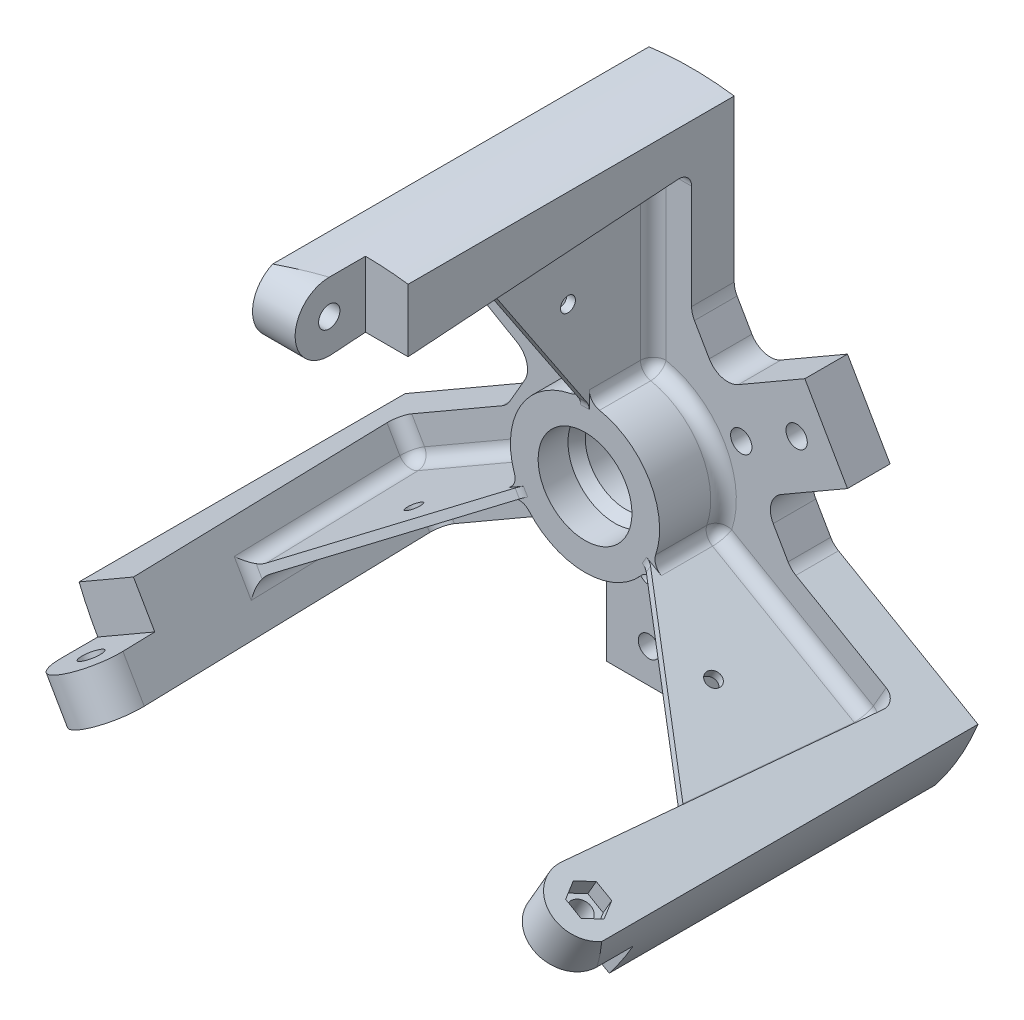
from build123d import *

# Parameters (mm, degrees)
SKETCH2_R           = 2.5
CUT_EXTRUDE1_DEPTH  = 86
CUT_EXTRUDE5_DEPTH  = 4.5
SKETCH8_R           = 2.5
BOSS_EXTRUDE2_DEPTH = 0.4
SKETCH10_R          = 1.75
BOSS_EXTRUDE3_DEPTH = 1
CIRPATTERN1_COUNT   = 3
BOSS_EXTRUDE1_DEPTH = 20
SKETCH4_R           = 2.5
CUT_EXTRUDE2_DEPTH  = 78.186714819
CUT_EXTRUDE3_DEPTH  = 10
CUT_EXTRUDE4_DEPTH  = 4
CIRPATTERN4_COUNT   = 3
SKETCH9_W           = 56.151894473
SKETCH9_H           = 118.300783097
FILLET1_R           = 3


with BuildPart() as part:
    # Sketch1 → Revolve1 (revolve)
    with BuildSketch(Plane(origin=(0, 0, 0), x_dir=(1, 0, 0), z_dir=(0, 1, 0)), mode=Mode.PRIVATE) as revolve1_sk:
        Polygon((11, 0), (11, -7), (9.5, -9.598076211), (9.5, -15.401923789), (11, -18), (11, -25), (17.5, -25), (17.5, -10), (62.5, -10), (62.5, -85), (72.5, -85), (72.5, 0), align=None)
    revolve(revolve1_sk.sketch.rotate(Axis((0, 0, 0), (0, 0, 1)), 180), axis=Axis((0, 0, 0), (0, 0, 1)))  # turned: the seam where the file's is

    # Sketch2 → Cut-Extrude1 (cut, through all)
    with BuildSketch(Plane.XY.offset(85)):
        with Locations((21.650635095, 12.5)):
            Circle(SKETCH2_R)
        with Locations((34.641016151, 20)):
            Circle(SKETCH2_R)
        with BuildLine():
            Line((10, 71.807033082), (10, 34.019237886))
            ThreePointArc((10, 34.019237886), (10.170370869, 32.725142661), (10.669872981, 31.519237886))
            Line((10.669872981, 31.519237886), (14.150635095, 25.490381057))
            ThreePointArc((14.150635095, 25.490381057), (17.186666888, 23.160751925), (20.980762114, 23.660254038))
            Line((20.980762114, 23.660254038), (36.569219382, 32.660254038))
            Line((36.569219382, 32.660254038), (46.569219382, 15.339745962))
            Line((46.569219382, 15.339745962), (30.980762114, 6.339745962))
            ThreePointArc((30.980762114, 6.339745962), (28.651132982, 3.303714169), (29.150635095, -0.490381057))
            Line((29.150635095, -0.490381057), (32.631397208, -6.519237886))
            ThreePointArc((32.631397208, -6.519237886), (33.425990321, -7.554771792), (34.461524227, -8.349364905))
            Line((34.461524227, -8.349364905), (67.186714819, -27.243262503))
            ThreePointArc((67.186714819, -27.243262503), (62.786841774, 36.25), (10, 71.807033082))
        make_face()
    cut_extrude1 = extrude(amount=-CUT_EXTRUDE1_DEPTH, mode=Mode.SUBTRACT)

    # Sketch7 → Cut-Extrude5 (cut)
    with BuildSketch(Plane(origin=(0, 0, 0), x_dir=(-1, 0, 0), z_dir=(0, 0, -1))):
        Polygon((-34.641016151, 24.156921938), (-38.241016151, 22.078460969), (-38.241016151, 17.921539031), (-34.641016151, 15.843078062), (-31.041016151, 17.921539031), (-31.041016151, 22.078460969), align=None)
        Polygon((-21.650635095, 16.656921938), (-25.250635095, 14.578460969), (-25.250635095, 10.421539031), (-21.650635095, 8.343078062), (-18.050635095, 10.421539031), (-18.050635095, 14.578460969), align=None)
    cut_extrude5 = extrude(amount=-CUT_EXTRUDE5_DEPTH, mode=Mode.SUBTRACT)

    # Sketch8 → Boss-Extrude2 (add)
    with BuildSketch(Plane(origin=(0, 0, 4.5), x_dir=(-1, 0, 0), z_dir=(0, 0, -1))):
        with Locations((-21.650635095, 12.5)):
            Circle(SKETCH8_R)
        with Locations((-34.641016151, 20)):
            Circle(SKETCH8_R)
    boss_extrude2 = extrude(amount=-BOSS_EXTRUDE2_DEPTH)

    # Sketch10 → Boss-Extrude3 (add, symmetric)
    with BuildSketch(Plane(origin=(0, 0, 0), x_dir=(0, 0, -1), z_dir=(1, 0, 0))):
        Polygon((-55, 62), (-25, 17), (-10, 17), (-10, 62), align=None)
        with Locations((-30, 40)):
            Circle(SKETCH10_R, mode=Mode.SUBTRACT)
    boss_extrude3 = extrude(amount=BOSS_EXTRUDE3_DEPTH, both=True)

    # CirPattern1: Cut-Extrude1, Cut-Extrude5, Boss-Extrude2, Boss-Extrude3 ×3 about axis
    cirpattern1_axis = Axis((0, 0, 0), (0, 0, 1))
    add([cut_extrude1.rotate(cirpattern1_axis, i * 360 / CIRPATTERN1_COUNT) for i in range(1, CIRPATTERN1_COUNT)], mode=Mode.SUBTRACT)
    add([cut_extrude5.rotate(cirpattern1_axis, i * 360 / CIRPATTERN1_COUNT) for i in range(1, CIRPATTERN1_COUNT)], mode=Mode.SUBTRACT)
    add([boss_extrude2.rotate(cirpattern1_axis, i * 360 / CIRPATTERN1_COUNT) for i in range(1, CIRPATTERN1_COUNT)])
    add([boss_extrude3.rotate(cirpattern1_axis, i * 360 / CIRPATTERN1_COUNT) for i in range(1, CIRPATTERN1_COUNT)])

    # Sketch3 → Boss-Extrude1 (add)
    with BuildSketch(Plane(origin=(10, 0, 0), x_dir=(0, 0, -1), z_dir=(1, 0, 0))):
        with BuildLine():
            Line((-84.445166078, 56.519263235), (-10, 61.694813396))
            Line((-10, 61.694813396), (-10, 72.5))
            Line((-10, 72.5), (-85, 72.5))
            ThreePointArc((-85, 72.5), (-92.995182741, 64.22241589), (-84.445166078, 56.519263235))
        make_face()
    boss_extrude1 = extrude(amount=-BOSS_EXTRUDE1_DEPTH)

    # Sketch4 → Cut-Extrude2 (cut, through all)
    with BuildSketch(Plane(origin=(10, 0, 0), x_dir=(0, 0, -1), z_dir=(1, 0, 0))):
        with Locations(Location((-85, 64.5, 0), (0, 0, 90))):  # turned: the seam where the file's is
            Circle(SKETCH4_R)
    cut_extrude2 = extrude(amount=-CUT_EXTRUDE2_DEPTH, mode=Mode.SUBTRACT)

    # Sketch5 → Cut-Extrude3 (cut)
    with BuildSketch(Plane(origin=(10, 0, 0), x_dir=(0, 0, -1), z_dir=(1, 0, 0))):
        with BuildLine():
            Line((-76.5, 72.5), (-85, 72.5))
            ThreePointArc((-85, 72.5), (-92.995182741, 64.22241589), (-84.445166078, 56.519263235))
            Line((-84.445166078, 56.519263235), (-76.5, 57.071624224))
            Line((-76.5, 57.071624224), (-76.5, 72.5))
        make_face()
    cut_extrude3 = extrude(amount=-CUT_EXTRUDE3_DEPTH, mode=Mode.SUBTRACT)

    # Sketch6 → Cut-Extrude4 (cut)
    with BuildSketch(Plane.ZY.offset(10)):
        Polygon((85, 60.343078062), (88.6, 62.421539031), (88.6, 66.578460969), (85, 68.656921938), (81.4, 66.578460969), (81.4, 62.421539031), align=None)
    cut_extrude4 = extrude(amount=-CUT_EXTRUDE4_DEPTH, mode=Mode.SUBTRACT)

    # CirPattern4: Boss-Extrude1, Cut-Extrude2, Cut-Extrude3, Cut-Extrude4 ×3 about axis
    cirpattern4_axis = Axis((0, 0, 0), (0, 0, 1))
    add([boss_extrude1.rotate(cirpattern4_axis, i * 360 / CIRPATTERN4_COUNT) for i in range(1, CIRPATTERN4_COUNT)])
    add([cut_extrude2.rotate(cirpattern4_axis, i * 360 / CIRPATTERN4_COUNT) for i in range(1, CIRPATTERN4_COUNT)], mode=Mode.SUBTRACT)
    add([cut_extrude3.rotate(cirpattern4_axis, i * 360 / CIRPATTERN4_COUNT) for i in range(1, CIRPATTERN4_COUNT)], mode=Mode.SUBTRACT)
    add([cut_extrude4.rotate(cirpattern4_axis, i * 360 / CIRPATTERN4_COUNT) for i in range(1, CIRPATTERN4_COUNT)], mode=Mode.SUBTRACT)

    # Sketch9 → Cut-Revolve1 (revolve, cut)
    with BuildSketch(Plane(origin=(0, 0, 0), x_dir=(1, 0, 0), z_dir=(0, 1, 0)), mode=Mode.PRIVATE) as cut_revolve1_sk:
        with Locations((100.575947236, -59.150391549)):
            Rectangle(SKETCH9_W, SKETCH9_H)
    revolve(cut_revolve1_sk.sketch.rotate(Axis((0, 0, 0), (0, 0, 1)), 180), axis=Axis((0, 0, 0), (0, 0, 1)), mode=Mode.SUBTRACT)  # turned: the seam where the file's is

    # Fillet1
    fillet1_edges = [part.edges().sort_by_distance(p)[0] for p in [
        (15.155444566, 8.75, 10),
        (-1, 39.583109303, 10),
        (1, 39.583109303, 10),
        (1, 17.47140521, 17.5),
        (-1, 17.47140521, 17.5),
        (0, 17, 25),
        (0, -17.5, 10),
        (34.779978217, -18.925529248, 10),
        (33.779978217, -20.657580055, 10),
        (14.630680751, -9.601728009, 17.5),
        (15.630680751, -7.869677201, 17.5),
        (14.722431864, -8.5, 25),
        (-15.155444566, 8.75, 10),
        (-33.779978217, -20.657580055, 10),
        (-34.779978217, -18.925529248, 10),
        (-15.630680751, -7.869677201, 17.5),
        (-14.630680751, -9.601728009, 17.5),
        (-14.722431864, -8.5, 25),
        (5.5, 61.694813396, 10),
        (-5.5, 61.694813396, 10),
        (-1, 60.206623104, 31.406144271),
        (1, 60.206623104, 31.406144271),
        (0, 58.718432812, 52.812288542),
        (50.851654486, -29.359216406, 52.812288542),
        (50.679275683, -35.610546419, 10),
        (56.179275683, -26.084266977, 10),
        (52.640465084, -29.237286148, 31.406144271),
        (51.640465084, -30.969336956, 31.406144271),
        (-50.851654486, -29.359216406, 52.812288542),
        (-56.179275683, -26.084266977, 10),
        (-50.679275683, -35.610546419, 10),
        (-51.640465084, -30.969336956, 31.406144271),
        (-52.640465084, -29.237286148, 31.406144271),
    ]]
    fillet(fillet1_edges, radius=FILLET1_R)


solid = part.part
